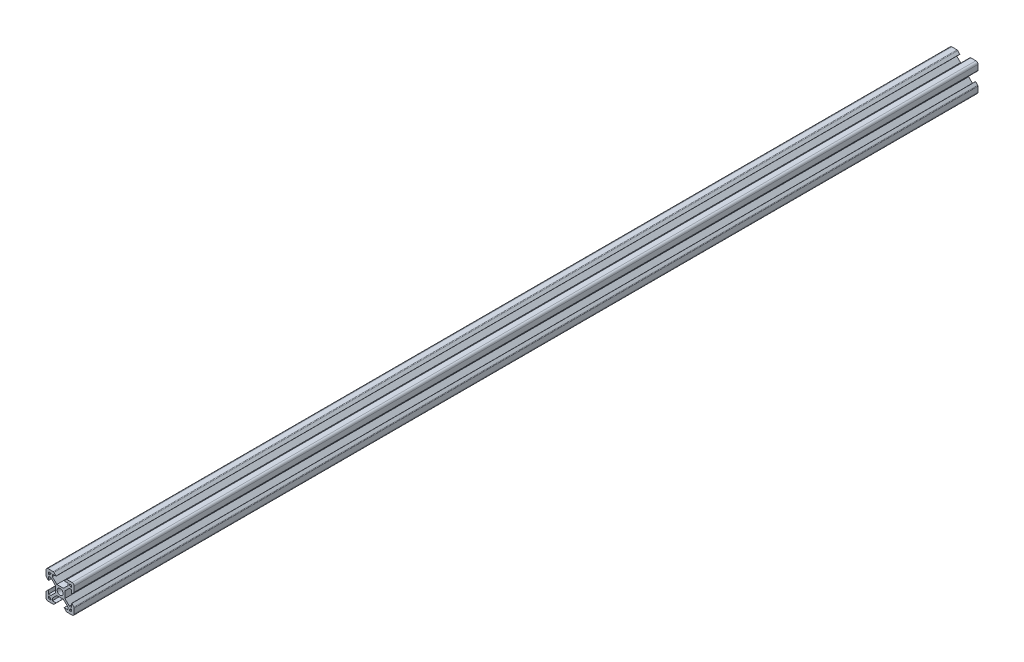
from build123d import *

# Parameters (mm, degrees)
SKETCH6_R           = 2.1
BOSS_EXTRUDE1_DEPTH = 640


with BuildPart() as part:
    # Sketch6 → Boss-Extrude1 (new body)
    with BuildSketch(Plane.XY):
        with BuildLine():
            Line((-3.4, -2.339339828), (-3.4, 2.339339828))
            Line((-3.4, 2.339339828), (-6.560660172, 5.5))
            Line((-6.560660172, 5.5), (-8.2, 5.5))
            Line((-8.2, 5.5), (-8.2, 2.89))
            Line((-8.2, 2.89), (-8.31, 2.89))
            Line((-8.31, 2.89), (-9.768614357, 4.348614357))
            ThreePointArc((-9.768614357, 4.348614357), (-9.939864831, 4.604908803), (-10, 4.907228714))
            Line((-10, 4.907228714), (-10, 8.5))
            ThreePointArc((-10, 8.5), (-9.560660172, 9.560660172), (-8.5, 10))
            Line((-8.5, 10), (-4.907228714, 10))
            ThreePointArc((-4.907228714, 10), (-4.604908803, 9.939864831), (-4.348614357, 9.768614357))
            Line((-4.348614357, 9.768614357), (-2.89, 8.31))
            Line((-2.89, 8.31), (-2.89, 8.2))
            Line((-2.89, 8.2), (-5.5, 8.2))
            Line((-5.5, 8.2), (-5.5, 6.560660172))
            Line((-5.5, 6.560660172), (-2.339339828, 3.4))
            Line((-2.339339828, 3.4), (2.339339828, 3.4))
            Line((2.339339828, 3.4), (5.5, 6.560660172))
            Line((5.5, 6.560660172), (5.5, 8.2))
            Line((5.5, 8.2), (2.89, 8.2))
            Line((2.89, 8.2), (2.89, 8.31))
            Line((2.89, 8.31), (4.348614357, 9.768614357))
            ThreePointArc((4.348614357, 9.768614357), (4.604908803, 9.939864831), (4.907228714, 10))
            Line((4.907228714, 10), (8.5, 10))
            ThreePointArc((8.5, 10), (9.560660172, 9.560660172), (10, 8.5))
            Line((10, 8.5), (10, 4.907228714))
            ThreePointArc((10, 4.907228714), (9.939864831, 4.604908803), (9.768614357, 4.348614357))
            Line((9.768614357, 4.348614357), (8.31, 2.89))
            Line((8.31, 2.89), (8.2, 2.89))
            Line((8.2, 2.89), (8.2, 5.5))
            Line((8.2, 5.5), (6.560660172, 5.5))
            Line((6.560660172, 5.5), (3.4, 2.339339828))
            Line((3.4, 2.339339828), (3.4, -2.339339828))
            Line((3.4, -2.339339828), (6.560660172, -5.5))
            Line((6.560660172, -5.5), (8.2, -5.5))
            Line((8.2, -5.5), (8.2, -2.89))
            Line((8.2, -2.89), (8.31, -2.89))
            Line((8.31, -2.89), (9.768614357, -4.348614357))
            ThreePointArc((9.768614357, -4.348614357), (9.939864831, -4.604908803), (10, -4.907228714))
            Line((10, -4.907228714), (10, -8.5))
            ThreePointArc((10, -8.5), (9.560660172, -9.560660172), (8.5, -10))
            Line((8.5, -10), (4.907228714, -10))
            ThreePointArc((4.907228714, -10), (4.604908803, -9.939864831), (4.348614357, -9.768614357))
            Line((4.348614357, -9.768614357), (2.89, -8.31))
            Line((2.89, -8.31), (2.89, -8.2))
            Line((2.89, -8.2), (5.5, -8.2))
            Line((5.5, -8.2), (5.5, -6.560660172))
            Line((5.5, -6.560660172), (2.339339828, -3.4))
            Line((2.339339828, -3.4), (-2.339339828, -3.4))
            Line((-2.339339828, -3.4), (-5.5, -6.560660172))
            Line((-5.5, -6.560660172), (-5.5, -8.2))
            Line((-5.5, -8.2), (-2.89, -8.2))
            Line((-2.89, -8.2), (-2.89, -8.31))
            Line((-2.89, -8.31), (-4.348614357, -9.768614357))
            ThreePointArc((-4.348614357, -9.768614357), (-4.604908803, -9.939864831), (-4.907228714, -10))
            Line((-4.907228714, -10), (-8.5, -10))
            ThreePointArc((-8.5, -10), (-9.560660172, -9.560660172), (-10, -8.5))
            Line((-10, -8.5), (-10, -4.907228714))
            ThreePointArc((-10, -4.907228714), (-9.939864831, -4.604908803), (-9.768614357, -4.348614357))
            Line((-9.768614357, -4.348614357), (-8.31, -2.89))
            Line((-8.31, -2.89), (-8.2, -2.89))
            Line((-8.2, -2.89), (-8.2, -5.5))
            Line((-8.2, -5.5), (-6.560660172, -5.5))
            Line((-6.560660172, -5.5), (-3.4, -2.339339828))
        make_face()
        Circle(SKETCH6_R, mode=Mode.SUBTRACT)
        Polygon((-7.66, 6.57), (-6.57, 7.66), (-6.57, 8.2), (-8.2, 8.2), (-8.2, 6.57), align=None, mode=Mode.SUBTRACT)
        Polygon((8.2, 6.57), (7.66, 6.57), (6.57, 7.66), (6.57, 8.2), (8.2, 8.2), align=None, mode=Mode.SUBTRACT)
        Polygon((7.66, -6.57), (6.57, -7.66), (6.57, -8.2), (8.2, -8.2), (8.2, -6.57), align=None, mode=Mode.SUBTRACT)
        Polygon((-8.2, -6.57), (-7.66, -6.57), (-6.57, -7.66), (-6.57, -8.2), (-8.2, -8.2), align=None, mode=Mode.SUBTRACT)
    extrude(amount=-BOSS_EXTRUDE1_DEPTH)


solid = part.part
